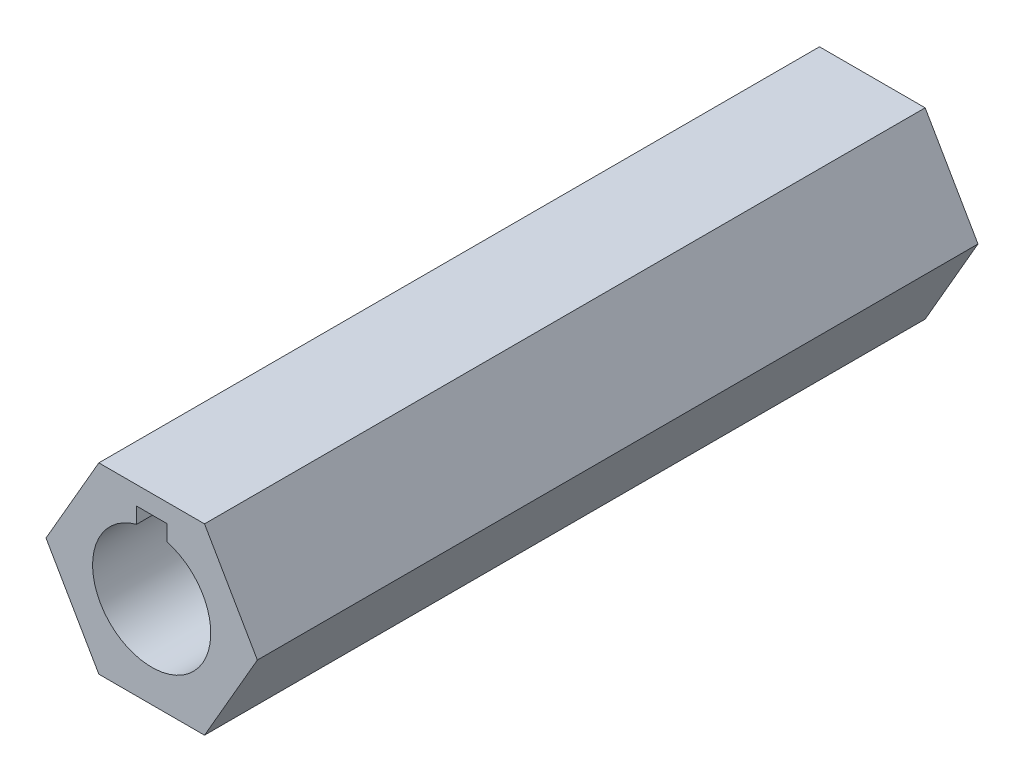
from build123d import *

# Parameters (mm, degrees)
BOSS_EXTRUDE1_DEPTH = 50
CUT_EXTRUDE1_DEPTH  = 51


with BuildPart() as part:
    # Sketch1 → Boss-Extrude1 (new body)
    with BuildSketch(Plane.XY):
        Polygon((7.332348419, 0), (3.666174209, 6.35), (-3.666174209, 6.35), (-7.332348419, 0), (-3.666174209, -6.35), (3.666174209, -6.35), align=None)
    extrude(amount=BOSS_EXTRUDE1_DEPTH)

    # Sketch2 → Cut-Extrude1 (cut, through all)
    with BuildSketch(Plane.XY.offset(50)):
        with BuildLine():
            Line((-1.048881406, 3.963565036), (-1.048881406, 5.062972332))
            Line((-1.048881406, 5.062972332), (1.051118594, 5.062972332))
            Line((1.051118594, 5.062972332), (1.051118594, 3.962972332))
            ThreePointArc((1.051118594, 3.962972332), (-0.001157185, -4.099999837), (-1.048881406, 3.963565036))
        make_face()
    extrude(amount=-CUT_EXTRUDE1_DEPTH, mode=Mode.SUBTRACT)


solid = part.part
